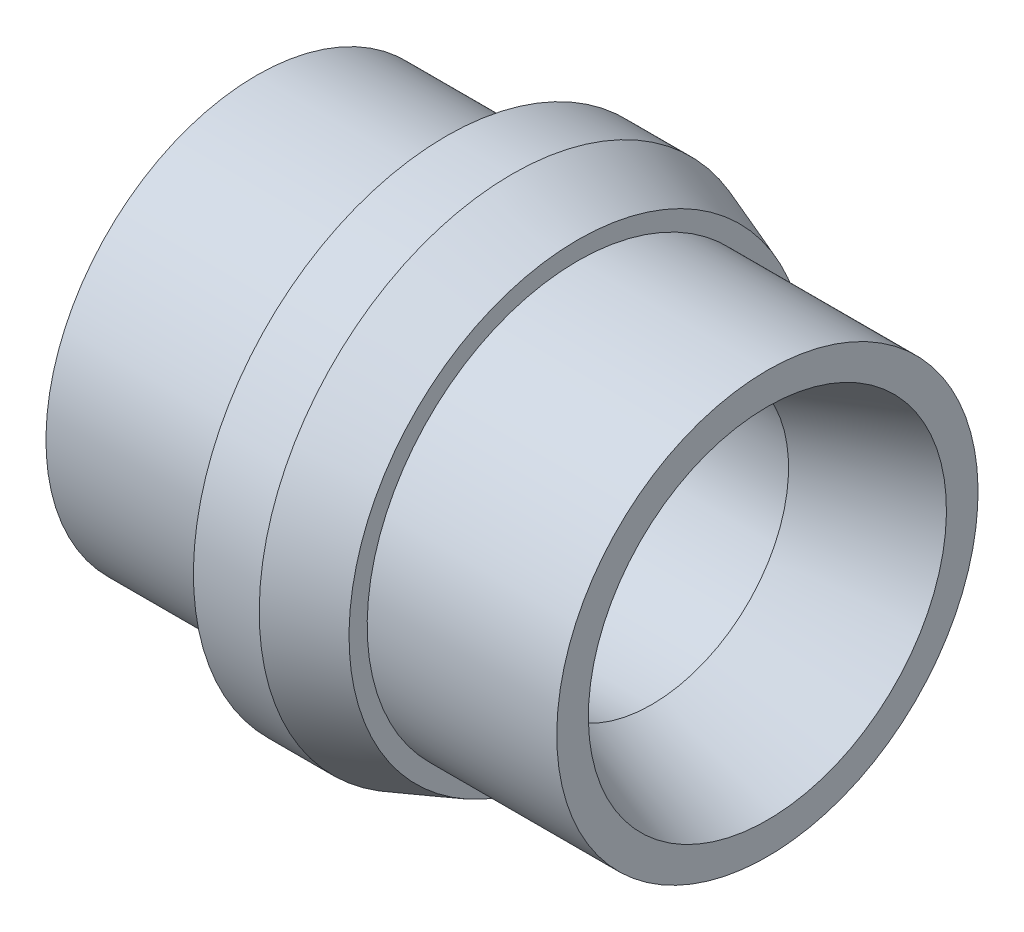
from build123d import *


with BuildPart() as part:
    # Sketch1 → Revolve1 (revolve)
    with BuildSketch(Plane.XY):
        Polygon((0, 6.096), (1.5875, 6.096), (3.175, 5.518197253), (3.175, 5.08), (7.747, 5.08), (7.747, 4.318), (4.955562942, 3.302), (-4.572, 3.302), (-4.572, 5.08), (0, 5.08), align=None)
    revolve(axis=Axis((3.868930609, 0, 0), (-1, 0, 0)))


solid = part.part
